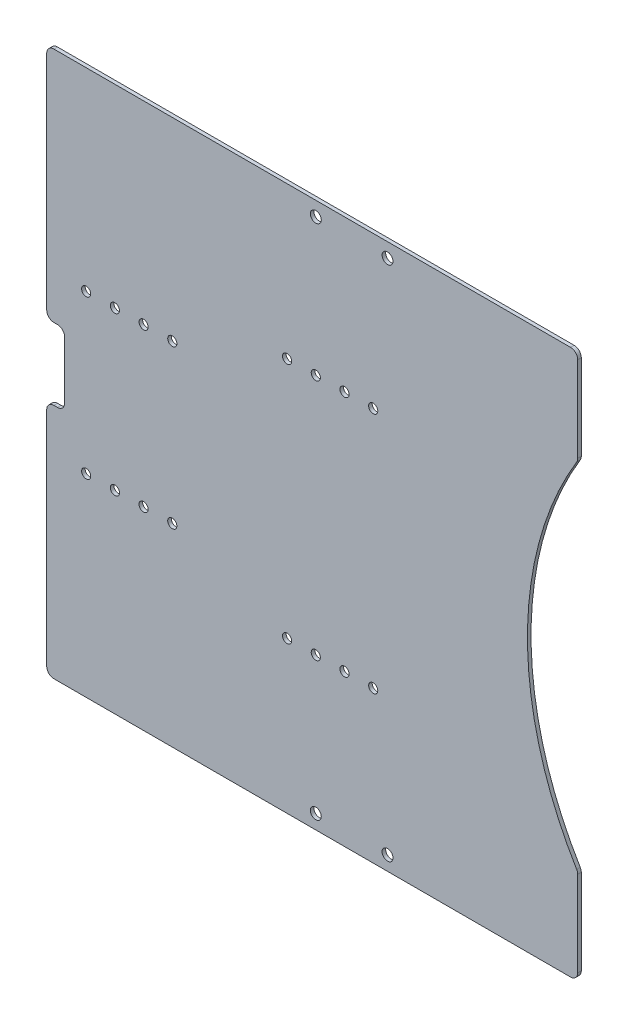
from build123d import *

# Parameters (mm, degrees)
SKETCH_1_W             = 89
SKETCH_1_H             = 152
SKETCH_1_R             = 1.525
EXTRUDE_1_DEPTH        = 0.5
SKETCH_2_R             = 1.275
CUT_EXTRUDE_1_DEPTH    = 5
SKETCH_4_W             = 29
SKETCH_4_H             = 152
EXTRUDE_3_DEPTH        = 1
SKETCH_5_R             = 95
CUT_EXTRUDE_3_DEPTH    = 22
SKETCH_9_W             = 30
SKETCH_9_H             = 152
EXTRUDE_4_DEPTH        = 1
PATTERN_LINEAR_1_COUNT = 4
PATTERN_LINEAR_1_PITCH = 8
SKETCH_10_W            = 10
SKETCH_10_H            = 20
CUT_EXTRUDE_4_DEPTH    = 10
FILLET_1_R             = 2


with BuildPart() as part:
    # 草图1 → 凸台-拉伸1 (new body, symmetric)
    with BuildSketch(Plane.XY):
        with Locations((-10.5, 0)):
            Rectangle(SKETCH_1_W, SKETCH_1_H)
        with Locations((-10, 72)):
            Circle(SKETCH_1_R, mode=Mode.SUBTRACT)
        with Locations((10, 72)):
            Circle(SKETCH_1_R, mode=Mode.SUBTRACT)
        with Locations((10, -72)):
            Circle(SKETCH_1_R, mode=Mode.SUBTRACT)
        with Locations((-10, -72)):
            Circle(SKETCH_1_R, mode=Mode.SUBTRACT)
    extrude(amount=EXTRUDE_1_DEPTH, both=True)

    # 草图2 → 切除-拉伸1 (cut, symmetric)
    with BuildSketch(Plane.XY.offset(0.5)):
        with Locations((-50, 22)):
            Circle(SKETCH_2_R)
        with Locations((-50, -22)):
            Circle(SKETCH_2_R)
        with Locations((6, -33.75)):
            Circle(SKETCH_2_R)
        with Locations((6, 33.75)):
            Circle(SKETCH_2_R)
    cut_extrude_1 = extrude(amount=CUT_EXTRUDE_1_DEPTH, both=True, mode=Mode.SUBTRACT)

    # 草图4 → 凸台-拉伸3 (add)
    with BuildSketch(Plane.XY.offset(0.5)):
        with Locations((48.5, 0)):
            Rectangle(SKETCH_4_W, SKETCH_4_H)
    extrude(amount=-EXTRUDE_3_DEPTH)

    # 草图5 → 切除-拉伸3 (cut)
    with BuildSketch(Plane.XY.offset(0.5)):
        with Locations((144, 0)):
            Circle(SKETCH_5_R)
    extrude(amount=-CUT_EXTRUDE_3_DEPTH, mode=Mode.SUBTRACT)

    # 草图9 → 凸台-拉伸4 (add)
    with BuildSketch(Plane.XY.offset(0.5)):
        with Locations((-70, 0)):
            Rectangle(SKETCH_9_W, SKETCH_9_H)
    extrude(amount=-EXTRUDE_4_DEPTH)

    # 阵列(线性)1: 切除-拉伸1 ×4
    with Locations(*[(-i * PATTERN_LINEAR_1_PITCH, 0, 0) for i in range(1, PATTERN_LINEAR_1_COUNT)]):
        add(cut_extrude_1, mode=Mode.SUBTRACT)

    # 草图10 → 切除-拉伸4 (cut)
    with BuildSketch(Plane.XY.offset(0.5)):
        with Locations((-85, 0)):
            Rectangle(SKETCH_10_W, SKETCH_10_H)
    extrude(amount=-CUT_EXTRUDE_4_DEPTH, mode=Mode.SUBTRACT)

    # 圆角1
    fillet_1_edges = [part.edges().sort_by_distance(p)[0] for p in [
        (-85, 10, 0),
        (-85, -10, 0),
        (-80, 10, 0),
        (-80, -10, 0),
        (63, 76, 0),
        (63, -76, 0),
        (63, -49.638694584, 0),
        (63, 49.638694584, 0),
        (-85, -76, 0),
        (-85, 76, 0),
    ]]
    fillet(fillet_1_edges, radius=FILLET_1_R)


solid = part.part
